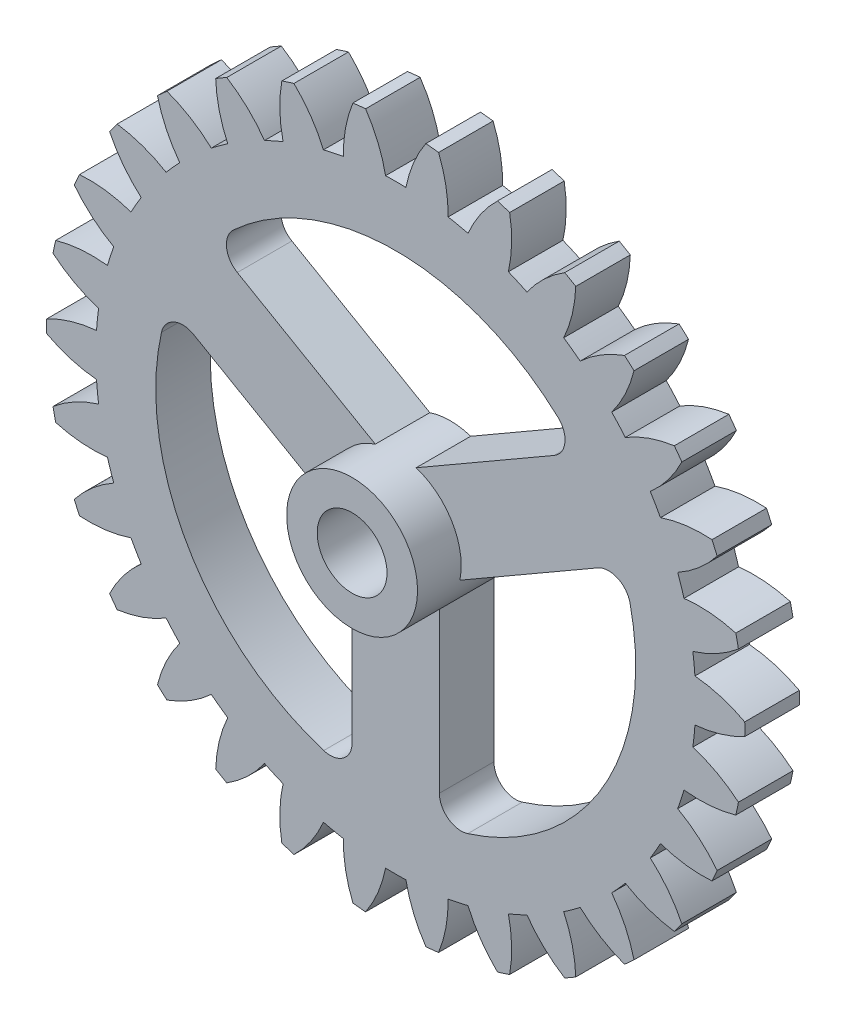
from build123d import *

# Parameters (mm, degrees)
BOSS_EXTRUDE1_DEPTH = 1.25
SKETCH3_R           = 1.5
CUT_EXTRUDE1_DEPTH  = 3.5
CUT_EXTRUDE2_DEPTH  = 3.5
SKETCH5_R           = 3
SKETCH5_R_2         = 1.5
BOSS_EXTRUDE2_DEPTH = 2
SKETCH6_R           = 1.6
CUT_EXTRUDE3_DEPTH  = 5.5


with BuildPart() as part:
    # Sketch1 → Boss-Extrude1 (new body, symmetric)
    with BuildSketch(Plane.XY):
        with BuildLine():
            ThreePointArc((-15.997323333, -0.292653692), (-14.890017219, -0.746983902), (-13.714564017, -0.972488982))
            ThreePointArc((-13.714564017, -0.972488982), (-13.673681539, -1.437161841), (-13.617059717, -1.900180429))
            ThreePointArc((-13.617059717, -1.900180429), (-14.719941304, -2.365148144), (-15.70858956, -3.039772036))
            ThreePointArc((-15.70858956, -3.039772036), (-15.650361612, -3.326587053), (-15.586897312, -3.612289049))
            ThreePointArc((-15.586897312, -3.612289049), (-14.409327931, -3.826469168), (-13.21267606, -3.802655958))
            ThreePointArc((-13.21267606, -3.802655958), (-13.076076043, -4.248674656), (-12.924424565, -4.689802838))
            ThreePointArc((-12.924424565, -4.689802838), (-13.90653332, -5.373911868), (-14.733315045, -6.23934514))
            ThreePointArc((-14.733315045, -6.23934514), (-14.616727322, -6.507786289), (-14.495249085, -6.774050041))
            ThreePointArc((-14.495249085, -6.774050041), (-13.29888187, -6.73871937), (-12.133330757, -6.466628622))
            ThreePointArc((-12.133330757, -6.466628622), (-11.906983277, -6.8745), (-11.666930042, -7.274458358))
            ThreePointArc((-11.666930042, -7.274458358), (-12.485343098, -8.147809856), (-13.114123965, -9.166228921))
            ThreePointArc((-13.114123965, -9.166228921), (-12.94427191, -9.404564037), (-12.770088917, -9.639752541))
            ThreePointArc((-12.770088917, -9.639752541), (-11.607210855, -9.356455199), (-10.523700679, -8.847978584))
            ThreePointArc((-10.523700679, -8.847978584), (-10.217498205, -9.199876707), (-9.899534691, -9.541185141))
            ThreePointArc((-9.899534691, -9.541185141), (-10.518483472, -10.565609456), (-10.921782738, -11.692504514))
            ThreePointArc((-10.921782738, -11.692504514), (-10.706089702, -11.890317208), (-10.486814585, -12.084151598))
            ThreePointArc((-10.486814585, -12.084151598), (-9.408249029, -11.565269039), (-8.454134382, -10.842629425))
            ThreePointArc((-8.454134382, -10.842629425), (-8.081459434, -11.123174656), (-7.699482172, -11.39091635))
            ThreePointArc((-7.699482172, -11.39091635), (-8.091915645, -12.521641223), (-8.252107198, -13.707761553))
            ThreePointArc((-8.252107198, -13.707761553), (-8, -13.856406461), (-7.745216135, -14.000415245))
            ThreePointArc((-7.745216135, -14.000415245), (-6.798101574, -13.268625126), (-6.015081845, -12.363405332))
            ThreePointArc((-6.015081845, -12.363405332), (-5.592222106, -12.560336497), (-5.162925335, -12.742809854))
            ThreePointArc((-5.162925335, -12.742809854), (-5.311692275, -13.930417183), (-5.221774975, -15.123923635))
            ThreePointArc((-5.221774975, -15.123923635), (-4.94427191, -15.216904261), (-4.665114574, -15.304793563))
            ThreePointArc((-4.665114574, -15.304793563), (-3.890844459, -14.392078624), (-3.313141369, -13.343841099))
            ThreePointArc((-3.313141369, -13.343841099), (-2.858577837, -13.448551362), (-2.400723887, -13.537781422))
            ThreePointArc((-2.400723887, -13.537781422), (-2.299322464, -14.730367067), (-1.963226128, -15.879097681))
            ThreePointArc((-1.963226128, -15.879097681), (-1.672455412, -15.912350326), (-1.38112512, -15.940278962))
            ThreePointArc((-1.38112512, -15.940278962), (-0.813538771, -14.886529226), (-0.466400716, -13.741086979))
            ThreePointArc((-0.466400716, -13.741086979), (0, -13.749), (0.466400716, -13.741086979))
            ThreePointArc((0.466400716, -13.741086979), (0.813538771, -14.886529226), (1.38112512, -15.940278962))
            ThreePointArc((1.38112512, -15.940278962), (1.672455412, -15.912350326), (1.963226128, -15.879097681))
            ThreePointArc((1.963226128, -15.879097681), (2.299322464, -14.730367067), (2.400723887, -13.537781422))
            ThreePointArc((2.400723887, -13.537781422), (2.858577837, -13.448551362), (3.313141369, -13.343841099))
            ThreePointArc((3.313141369, -13.343841099), (3.890844459, -14.392078624), (4.665114574, -15.304793563))
            ThreePointArc((4.665114574, -15.304793563), (4.94427191, -15.216904261), (5.221774975, -15.123923635))
            ThreePointArc((5.221774975, -15.123923635), (5.311692275, -13.930417183), (5.162925335, -12.742809854))
            ThreePointArc((5.162925335, -12.742809854), (5.592222106, -12.560336497), (6.015081845, -12.363405332))
            ThreePointArc((6.015081845, -12.363405332), (6.798101574, -13.268625126), (7.745216135, -14.000415245))
            ThreePointArc((7.745216135, -14.000415245), (8, -13.856406461), (8.252107198, -13.707761553))
            ThreePointArc((8.252107198, -13.707761553), (8.091915645, -12.521641223), (7.699482172, -11.39091635))
            ThreePointArc((7.699482172, -11.39091635), (8.081459434, -11.123174656), (8.454134382, -10.842629425))
            ThreePointArc((8.454134382, -10.842629425), (9.408249029, -11.565269039), (10.486814585, -12.084151598))
            ThreePointArc((10.486814585, -12.084151598), (10.706089702, -11.890317208), (10.921782738, -11.692504514))
            ThreePointArc((10.921782738, -11.692504514), (10.518483472, -10.565609456), (9.899534691, -9.541185141))
            ThreePointArc((9.899534691, -9.541185141), (10.217498205, -9.199876707), (10.523700679, -8.847978584))
            ThreePointArc((10.523700679, -8.847978584), (11.607210855, -9.356455199), (12.770088917, -9.639752541))
            ThreePointArc((12.770088917, -9.639752541), (12.94427191, -9.404564037), (13.114123965, -9.166228921))
            ThreePointArc((13.114123965, -9.166228921), (12.485343098, -8.147809856), (11.666930042, -7.274458358))
            ThreePointArc((11.666930042, -7.274458358), (11.906983277, -6.8745), (12.133330757, -6.466628622))
            ThreePointArc((12.133330757, -6.466628622), (13.29888187, -6.73871937), (14.495249085, -6.774050041))
            ThreePointArc((14.495249085, -6.774050041), (14.616727322, -6.507786289), (14.733315045, -6.23934514))
            ThreePointArc((14.733315045, -6.23934514), (13.90653332, -5.373911868), (12.924424565, -4.689802838))
            ThreePointArc((12.924424565, -4.689802838), (13.076076043, -4.248674656), (13.21267606, -3.802655958))
            ThreePointArc((13.21267606, -3.802655958), (14.409327931, -3.826469168), (15.586897312, -3.612289049))
            ThreePointArc((15.586897312, -3.612289049), (15.650361612, -3.326587053), (15.70858956, -3.039772036))
            ThreePointArc((15.70858956, -3.039772036), (14.719941304, -2.365148144), (13.617059717, -1.900180429))
            ThreePointArc((13.617059717, -1.900180429), (13.673681539, -1.437161841), (13.714564017, -0.972488982))
            ThreePointArc((13.714564017, -0.972488982), (14.890017219, -0.746983902), (15.997323333, -0.292653692))
            ThreePointArc((15.997323333, -0.292653692), (16, 0), (15.997323333, 0.292653692))
            ThreePointArc((15.997323333, 0.292653692), (14.890017219, 0.746983902), (13.714564017, 0.972488982))
            ThreePointArc((13.714564017, 0.972488982), (13.673681539, 1.437161841), (13.617059717, 1.900180429))
            ThreePointArc((13.617059717, 1.900180429), (14.719941304, 2.365148144), (15.70858956, 3.039772036))
            ThreePointArc((15.70858956, 3.039772036), (15.650361612, 3.326587053), (15.586897312, 3.612289049))
            ThreePointArc((15.586897312, 3.612289049), (14.409327931, 3.826469168), (13.21267606, 3.802655958))
            ThreePointArc((13.21267606, 3.802655958), (13.076076043, 4.248674656), (12.924424565, 4.689802838))
            ThreePointArc((12.924424565, 4.689802838), (13.90653332, 5.373911868), (14.733315045, 6.23934514))
            ThreePointArc((14.733315045, 6.23934514), (14.616727322, 6.507786289), (14.495249085, 6.774050041))
            ThreePointArc((14.495249085, 6.774050041), (13.29888187, 6.73871937), (12.133330757, 6.466628622))
            ThreePointArc((12.133330757, 6.466628622), (11.906983277, 6.8745), (11.666930042, 7.274458358))
            ThreePointArc((11.666930042, 7.274458358), (12.485343098, 8.147809856), (13.114123965, 9.166228921))
            ThreePointArc((13.114123965, 9.166228921), (12.94427191, 9.404564037), (12.770088917, 9.639752541))
            ThreePointArc((12.770088917, 9.639752541), (11.607210855, 9.356455199), (10.523700679, 8.847978584))
            ThreePointArc((10.523700679, 8.847978584), (10.217498205, 9.199876707), (9.899534691, 9.541185141))
            ThreePointArc((9.899534691, 9.541185141), (10.518483472, 10.565609456), (10.921782738, 11.692504514))
            ThreePointArc((10.921782738, 11.692504514), (10.706089702, 11.890317208), (10.486814585, 12.084151598))
            ThreePointArc((10.486814585, 12.084151598), (9.408249029, 11.565269039), (8.454134382, 10.842629425))
            ThreePointArc((8.454134382, 10.842629425), (8.081459434, 11.123174656), (7.699482172, 11.39091635))
            ThreePointArc((7.699482172, 11.39091635), (8.091915645, 12.521641223), (8.252107198, 13.707761553))
            ThreePointArc((8.252107198, 13.707761553), (8, 13.856406461), (7.745216135, 14.000415245))
            ThreePointArc((7.745216135, 14.000415245), (6.798101574, 13.268625126), (6.015081845, 12.363405332))
            ThreePointArc((6.015081845, 12.363405332), (5.592222106, 12.560336497), (5.162925335, 12.742809854))
            ThreePointArc((5.162925335, 12.742809854), (5.311692275, 13.930417183), (5.221774975, 15.123923635))
            ThreePointArc((5.221774975, 15.123923635), (4.94427191, 15.216904261), (4.665114574, 15.304793563))
            ThreePointArc((4.665114574, 15.304793563), (3.890844459, 14.392078624), (3.313141369, 13.343841099))
            ThreePointArc((3.313141369, 13.343841099), (2.858577837, 13.448551362), (2.400723887, 13.537781422))
            ThreePointArc((2.400723887, 13.537781422), (2.299322464, 14.730367067), (1.963226128, 15.879097681))
            ThreePointArc((1.963226128, 15.879097681), (1.672455412, 15.912350326), (1.38112512, 15.940278962))
            ThreePointArc((1.38112512, 15.940278962), (0.813538771, 14.886529226), (0.466400716, 13.741086979))
            ThreePointArc((0.466400716, 13.741086979), (0, 13.749), (-0.466400716, 13.741086979))
            ThreePointArc((-0.466400716, 13.741086979), (-0.813538771, 14.886529226), (-1.38112512, 15.940278962))
            ThreePointArc((-1.38112512, 15.940278962), (-1.672455412, 15.912350326), (-1.963226128, 15.879097681))
            ThreePointArc((-1.963226128, 15.879097681), (-2.299322464, 14.730367067), (-2.400723887, 13.537781422))
            ThreePointArc((-2.400723887, 13.537781422), (-2.858577837, 13.448551362), (-3.313141369, 13.343841099))
            ThreePointArc((-3.313141369, 13.343841099), (-3.890844459, 14.392078624), (-4.665114574, 15.304793563))
            ThreePointArc((-4.665114574, 15.304793563), (-4.94427191, 15.216904261), (-5.221774975, 15.123923635))
            ThreePointArc((-5.221774975, 15.123923635), (-5.311692275, 13.930417183), (-5.162925335, 12.742809854))
            ThreePointArc((-5.162925335, 12.742809854), (-5.592222106, 12.560336497), (-6.015081845, 12.363405332))
            ThreePointArc((-6.015081845, 12.363405332), (-6.798101574, 13.268625126), (-7.745216135, 14.000415245))
            ThreePointArc((-7.745216135, 14.000415245), (-8, 13.856406461), (-8.252107198, 13.707761553))
            ThreePointArc((-8.252107198, 13.707761553), (-8.091915645, 12.521641223), (-7.699482172, 11.39091635))
            ThreePointArc((-7.699482172, 11.39091635), (-8.081459434, 11.123174656), (-8.454134382, 10.842629425))
            ThreePointArc((-8.454134382, 10.842629425), (-9.408249029, 11.565269039), (-10.486814585, 12.084151598))
            ThreePointArc((-10.486814585, 12.084151598), (-10.706089702, 11.890317208), (-10.921782738, 11.692504514))
            ThreePointArc((-10.921782738, 11.692504514), (-10.518483472, 10.565609456), (-9.899534691, 9.541185141))
            ThreePointArc((-9.899534691, 9.541185141), (-10.217498205, 9.199876707), (-10.523700679, 8.847978584))
            ThreePointArc((-10.523700679, 8.847978584), (-11.607210855, 9.356455199), (-12.770088917, 9.639752541))
            ThreePointArc((-12.770088917, 9.639752541), (-12.94427191, 9.404564037), (-13.114123965, 9.166228921))
            ThreePointArc((-13.114123965, 9.166228921), (-12.485343098, 8.147809856), (-11.666930042, 7.274458358))
            ThreePointArc((-11.666930042, 7.274458358), (-11.906983277, 6.8745), (-12.133330757, 6.466628622))
            ThreePointArc((-12.133330757, 6.466628622), (-13.29888187, 6.73871937), (-14.495249085, 6.774050041))
            ThreePointArc((-14.495249085, 6.774050041), (-14.616727322, 6.507786289), (-14.733315045, 6.23934514))
            ThreePointArc((-14.733315045, 6.23934514), (-13.90653332, 5.373911868), (-12.924424565, 4.689802838))
            ThreePointArc((-12.924424565, 4.689802838), (-13.076076043, 4.248674656), (-13.21267606, 3.802655958))
            ThreePointArc((-13.21267606, 3.802655958), (-14.409327931, 3.826469168), (-15.586897312, 3.612289049))
            ThreePointArc((-15.586897312, 3.612289049), (-15.650361612, 3.326587053), (-15.70858956, 3.039772036))
            ThreePointArc((-15.70858956, 3.039772036), (-14.719941304, 2.365148144), (-13.617059717, 1.900180429))
            ThreePointArc((-13.617059717, 1.900180429), (-13.673681539, 1.437161841), (-13.714564017, 0.972488982))
            ThreePointArc((-13.714564017, 0.972488982), (-14.890017219, 0.746983902), (-15.997323333, 0.292653692))
            ThreePointArc((-15.997323333, 0.292653692), (-16, 0), (-15.997323333, -0.292653692))
        make_face()
    extrude(amount=BOSS_EXTRUDE1_DEPTH, both=True)

    # Sketch3 → Cut-Extrude1 (cut, through all)
    with BuildSketch(Plane.XY.offset(1.25)):
        Circle(SKETCH3_R)
    extrude(amount=-CUT_EXTRUDE1_DEPTH, mode=Mode.SUBTRACT)

    # Sketch4 → Cut-Extrude2 (cut, through all)
    with BuildSketch(Plane.XY.offset(1.25)):
        with BuildLine():
            Line((0.936491673, 2.850084796), (7.261355821, 6.501746815))
            ThreePointArc((7.261355821, 6.501746815), (7.755371812, 7.258537568), (7.437491403, 8.10454944))
            ThreePointArc((7.437491403, 8.10454944), (0, 11), (-7.437491403, 8.10454944))
            ThreePointArc((-7.437491403, 8.10454944), (-7.755371812, 7.258537568), (-7.261355821, 6.501746815))
            Line((-7.261355821, 6.501746815), (-0.936491673, 2.850084796))
            ThreePointArc((-0.936491673, 2.850084796), (0, 3), (0.936491673, 2.850084796))
        make_face()
        with BuildLine():
            Line((2, -2.236067978), (2, -9.539392014))
            ThreePointArc((2, -9.539392014), (2.408392022, -10.345617789), (3.3, -10.493331216))
            ThreePointArc((3.3, -10.493331216), (9.526279442, -5.5), (10.737491403, 2.388781775))
            ThreePointArc((10.737491403, 2.388781775), (10.163763834, 3.087080221), (9.261355821, 3.0376452))
            Line((9.261355821, 3.0376452), (2.936491673, -0.614016819))
            ThreePointArc((2.936491673, -0.614016819), (2.598076211, -1.5), (2, -2.236067978))
        make_face()
        with BuildLine():
            Line((-2.936491673, -0.614016819), (-9.261355821, 3.0376452))
            ThreePointArc((-9.261355821, 3.0376452), (-10.163763834, 3.087080221), (-10.737491403, 2.388781775))
            ThreePointArc((-10.737491403, 2.388781775), (-9.526279442, -5.5), (-3.3, -10.493331216))
            ThreePointArc((-3.3, -10.493331216), (-2.408392022, -10.345617789), (-2, -9.539392014))
            Line((-2, -9.539392014), (-2, -2.236067978))
            ThreePointArc((-2, -2.236067978), (-2.598076211, -1.5), (-2.936491673, -0.614016819))
        make_face()
    extrude(amount=-CUT_EXTRUDE2_DEPTH, mode=Mode.SUBTRACT)

    # Sketch5 → Boss-Extrude2 (add)
    with BuildSketch(Plane.XY.offset(1.25)):
        Circle(SKETCH5_R)
        Circle(SKETCH5_R_2, mode=Mode.SUBTRACT)
    extrude(amount=BOSS_EXTRUDE2_DEPTH)

    # Sketch6 → Cut-Extrude3 (cut, through all)
    with BuildSketch(Plane.XY.offset(3.25)):
        Circle(SKETCH6_R)
    extrude(amount=-CUT_EXTRUDE3_DEPTH, mode=Mode.SUBTRACT)


solid = part.part
